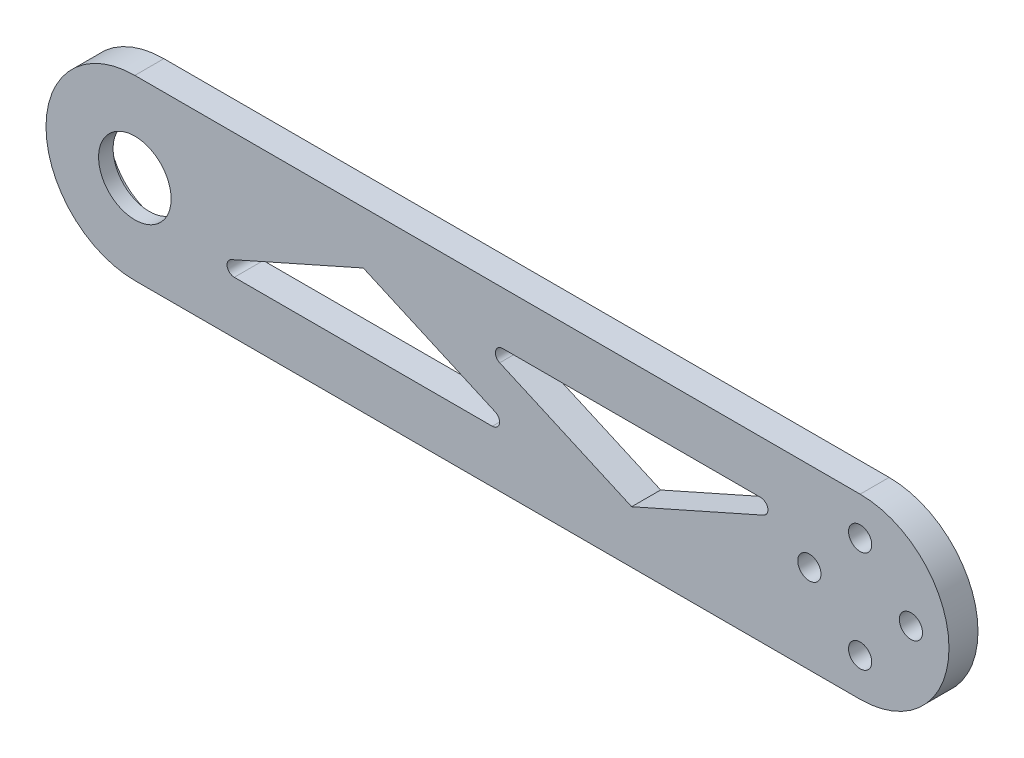
from build123d import *

# Parameters (mm, degrees)
SKETCH_1_R          = 5
SKETCH_1_R_2        = 1.6
EXTRUDE_1_DEPTH     = 4
SKETCH_4_R          = 7.5
CUT_EXTRUDE_3_DEPTH = 3
CUT_EXTRUDE_4_REACH = 6


with BuildPart() as part:
    # 草图1 → 凸台-拉伸1 (new body)
    with BuildSketch(Plane.XY):
        with BuildLine():
            Line((0, 12.25), (100, 12.25))
            ThreePointArc((100, 12.25), (112.25, 0), (100, -12.25))
            Line((100, -12.25), (0, -12.25))
            ThreePointArc((0, -12.25), (-12.25, 0), (0, 12.25))
        make_face()
        Circle(SKETCH_1_R, mode=Mode.SUBTRACT)
        with Locations((100, 7)):
            Circle(SKETCH_1_R_2, mode=Mode.SUBTRACT)
        with Locations((107, 0)):
            Circle(SKETCH_1_R_2, mode=Mode.SUBTRACT)
        with Locations((100, -7)):
            Circle(SKETCH_1_R_2, mode=Mode.SUBTRACT)
        with Locations((93, 0)):
            Circle(SKETCH_1_R_2, mode=Mode.SUBTRACT)
    extrude(amount=EXTRUDE_1_DEPTH)

    # 草图4 → 切除-拉伸3 (cut)
    with BuildSketch(Plane.XY.offset(2)):
        Circle(SKETCH_4_R)
    extrude(amount=-CUT_EXTRUDE_3_DEPTH, mode=Mode.SUBTRACT)

    # 草图5 → 切除-拉伸4 (cut, up to next)
    with BuildSketch(Plane.XY.offset(4), mode=Mode.PRIVATE) as cut_extrude_4_sk1:
        with BuildLine():
            Line((31.5, 5), (13.306075984, -3.086188451))
            ThreePointArc((13.306075984, -3.086188451), (12.733998843, -4.207591488), (13.71221445, -5))
            Line((13.71221445, -5), (49.28778555, -5))
            ThreePointArc((49.28778555, -5), (50.266001157, -4.207591488), (49.693924016, -3.086188451))
            Line((49.693924016, -3.086188451), (31.5, 5))
        make_face()
    cut_extrude_4_tool1 = extrude(cut_extrude_4_sk1.sketch, amount=-CUT_EXTRUDE_4_REACH, mode=Mode.PRIVATE) & part.part
    add(cut_extrude_4_tool1.solids().sort_by_distance((31.5, -1.58127, 4))[0], mode=Mode.SUBTRACT)
    # 草图5 → 切除-拉伸4 (cut, up to next)
    with BuildSketch(Plane.XY.offset(4), mode=Mode.PRIVATE) as cut_extrude_4_sk2:
        with BuildLine():
            Line((68.5, -5), (86.693924016, 3.086188451))
            ThreePointArc((86.693924016, 3.086188451), (87.266001157, 4.207591488), (86.28778555, 5))
            Line((86.28778555, 5), (50.71221445, 5))
            ThreePointArc((50.71221445, 5), (49.733998843, 4.207591488), (50.306075984, 3.086188451))
            Line((50.306075984, 3.086188451), (68.5, -5))
        make_face()
    cut_extrude_4_tool2 = extrude(cut_extrude_4_sk2.sketch, amount=-CUT_EXTRUDE_4_REACH, mode=Mode.PRIVATE) & part.part
    add(cut_extrude_4_tool2.solids().sort_by_distance((68.5, 1.58127, 4))[0], mode=Mode.SUBTRACT)


solid = part.part
